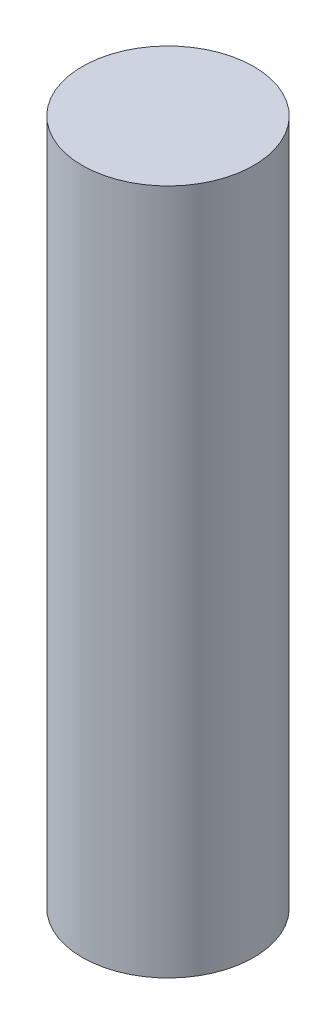
from build123d import *

# Parameters (mm, degrees)
SKETCH1_R           = 25
BOSS_EXTRUDE1_DEPTH = 100


with BuildPart() as part:
    # Sketch1 → Boss-Extrude1 (new body, symmetric)
    with BuildSketch(Plane(origin=(0, 0, 0), x_dir=(1, 0, 0), z_dir=(0, 1, 0))):
        Circle(SKETCH1_R)
    extrude(amount=BOSS_EXTRUDE1_DEPTH, both=True)


solid = part.part
